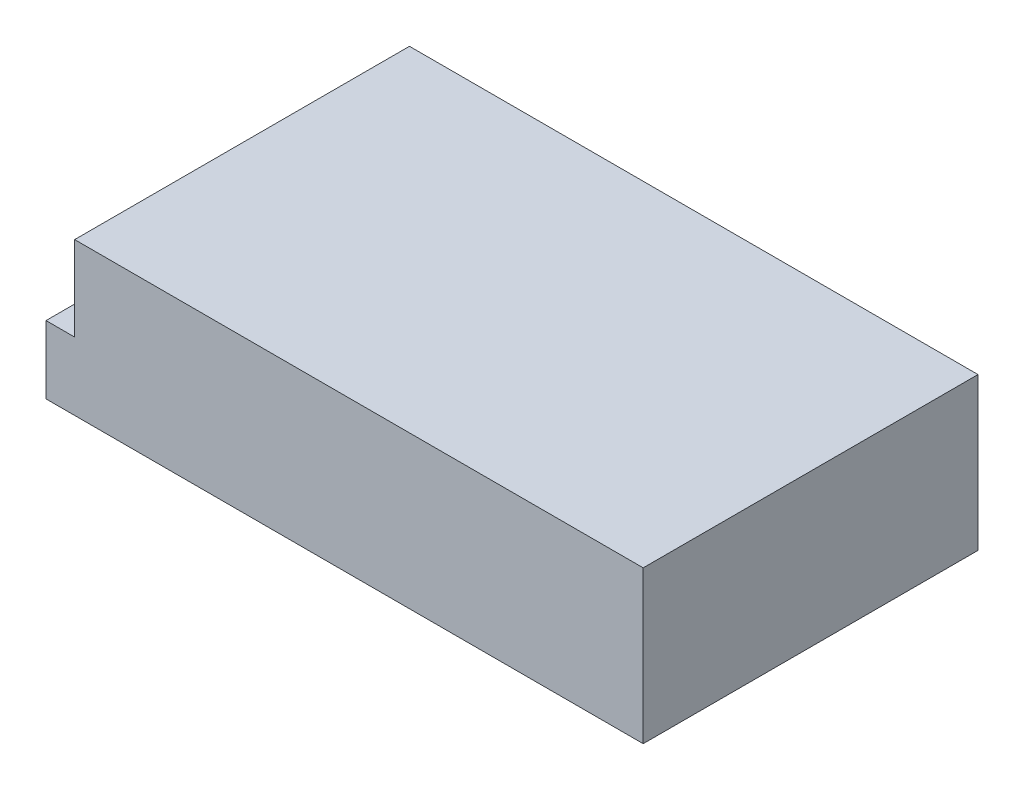
from build123d import *

# Parameters (mm, degrees)
SKETCH1_W           = 198
SKETCH1_H           = 111
BOSS_EXTRUDE1_DEPTH = 50.5
SKETCH2_W           = 9.5
SKETCH2_H           = 28
CUT_EXTRUDE1_DEPTH  = 147.5
SKETCH4_R           = 1.5
CUT_EXTRUDE2_DEPTH  = 3


with BuildPart() as part:
    # Sketch1 → Boss-Extrude1 (new body)
    with BuildSketch(Plane(origin=(0, 0, 0), x_dir=(1, 0, 0), z_dir=(0, 1, 0))):
        Rectangle(SKETCH1_W, SKETCH1_H)
    extrude(amount=BOSS_EXTRUDE1_DEPTH)

    # Sketch2 → Cut-Extrude1 (cut)
    with BuildSketch(Plane(origin=(0, 0, -55.5), x_dir=(-1, 0, 0), z_dir=(0, 0, -1))):
        with Locations((94.25, 36.5)):
            Rectangle(SKETCH2_W, SKETCH2_H)
    extrude(amount=-CUT_EXTRUDE1_DEPTH, mode=Mode.SUBTRACT)

    # Sketch4 → Cut-Extrude2 (cut)
    with BuildSketch(Plane.XZ):
        with Locations((87, 39.5)):
            Circle(SKETCH4_R)
        with Locations((87, -45.5)):
            Circle(SKETCH4_R)
        with Locations((-39, 39.5)):
            Circle(SKETCH4_R)
        with Locations((-39, -45.5)):
            Circle(SKETCH4_R)
    extrude(amount=-CUT_EXTRUDE2_DEPTH, mode=Mode.SUBTRACT)


solid = part.part
